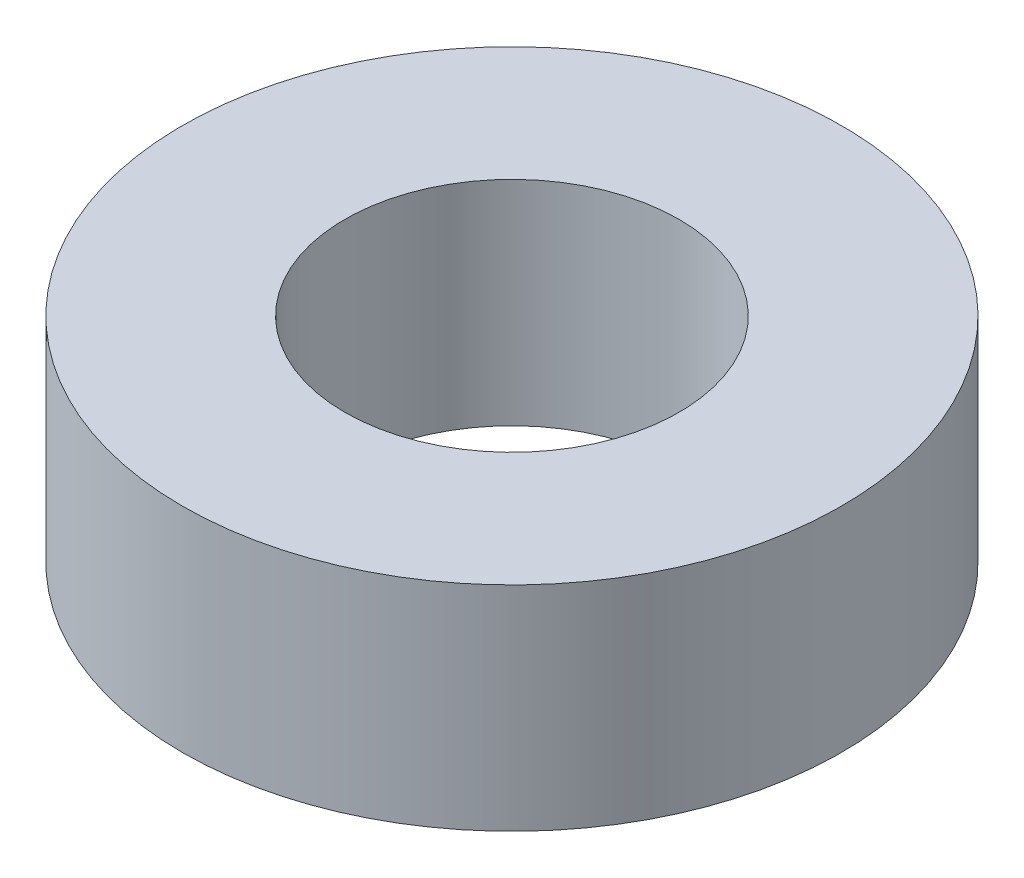
from build123d import *

# Parameters (mm, degrees)
ESQUISSE1_R        = 13.9
ESQUISSE1_R_2      = 7.05
BOSS_EXTRU_1_DEPTH = 9


with BuildPart() as part:
    # Esquisse1 → Boss.-Extru.1 (new body)
    with BuildSketch(Plane(origin=(0, 0, 0), x_dir=(1, 0, 0), z_dir=(0, 1, 0))):
        with Locations(Location((0, 0, 0), (0, 0, 270))):  # turned: the seam where the file's is
            Circle(ESQUISSE1_R)
        with Locations(Location((0, 0, 0), (0, 0, 270))):  # turned: the seam where the file's is
            Circle(ESQUISSE1_R_2, mode=Mode.SUBTRACT)
    extrude(amount=BOSS_EXTRU_1_DEPTH)


solid = part.part
